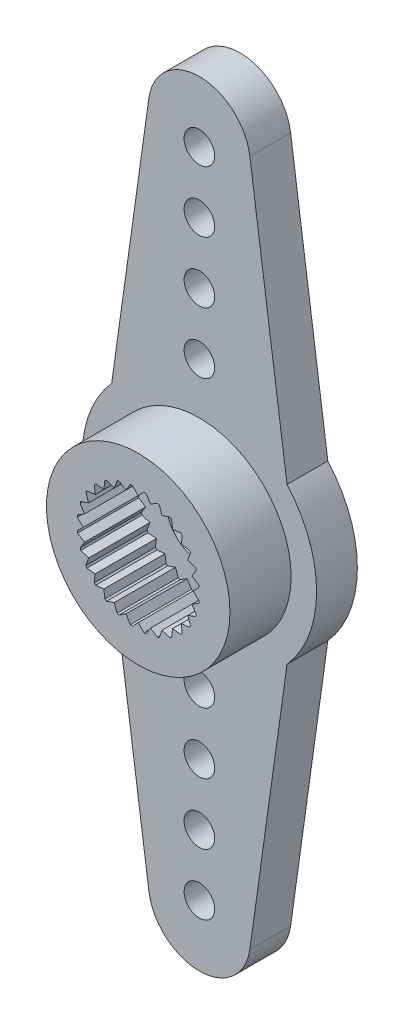
from build123d import *

# Parameters (mm, degrees)
ESQUISSE1_R                  = 5.75
ESQUISSE1_R_2                = 1.6
BOSS_EXTRU_1_DEPTH           = 5
ESQUISSE2_R                  = 3
ENL_V_MAT_EXTRU_1_DEPTH      = 3
ESQUISSE3_R                  = 5.75
ESQUISSE3_R_2                = 4.5
ENL_V_MAT_EXTRU_2_DEPTH      = 3
BOSS_EXTRU_2_DEPTH           = 2
R_P_TITION_CIRCULAIRE1_COUNT = 2
ESQUISSE5_R                  = 0.75
ENL_V_MAT_EXTRU_3_DEPTH      = 3
R_P_TITION_CIRCULAIRE2_COUNT = 2
BOSS_EXTRU_3_DEPTH           = 3
R_P_TITION_CIRCULAIRE3_COUNT = 28
ESQUISSE7_R                  = 3
ESQUISSE7_R_2                = 1.6
ENL_V_MAT_EXTRU_4_DEPTH      = 1
ESQUISSE8_R                  = 4.7
ESQUISSE8_R_2                = 3.4
ENL_V_MAT_EXTRU_5_DEPTH      = 1


with BuildPart() as part:
    # Esquisse1 → Boss.-Extru.1 (new body)
    with BuildSketch(Plane.XY):
        Circle(ESQUISSE1_R)
        Circle(ESQUISSE1_R_2, mode=Mode.SUBTRACT)
    extrude(amount=BOSS_EXTRU_1_DEPTH)

    # Esquisse2 → Enlèv. mat.-Extru.1 (cut)
    with BuildSketch(Plane.XY.offset(5)):
        Circle(ESQUISSE2_R)
    extrude(amount=-ENL_V_MAT_EXTRU_1_DEPTH, mode=Mode.SUBTRACT)

    # Esquisse3 → Enlèv. mat.-Extru.2 (cut)
    with BuildSketch(Plane.XY.offset(5)):
        Circle(ESQUISSE3_R)
        Circle(ESQUISSE3_R_2, mode=Mode.SUBTRACT)
    extrude(amount=-ENL_V_MAT_EXTRU_2_DEPTH, mode=Mode.SUBTRACT)

    # Esquisse4 → Boss.-Extru.2 (add)
    with BuildSketch(Plane(origin=(0, 0, 0), x_dir=(-1, 0, 0), z_dir=(0, 0, -1))):
        with BuildLine():
            Line((-4.3, 3.817394399), (-2.475852955, 16.846629695))
            ThreePointArc((-2.475852955, 16.846629695), (0, 19), (2.475852955, 16.846629695))
            Line((2.475852955, 16.846629695), (4.3, 3.817394399))
            ThreePointArc((4.3, 3.817394399), (0, 5.75), (-4.3, 3.817394399))
        make_face()
    boss_extru_2 = extrude(amount=-BOSS_EXTRU_2_DEPTH)

    # Répétition circulaire1: Boss.-Extru.2 ×2 about axis
    r_p_tition_circulaire1_axis = Axis((0, 0, 0), (0, 0, 1))
    for i in range(1, R_P_TITION_CIRCULAIRE1_COUNT):
        add(boss_extru_2.rotate(r_p_tition_circulaire1_axis, i * 360 / R_P_TITION_CIRCULAIRE1_COUNT))

    # Esquisse5 → Enlèv. mat.-Extru.3 (cut)
    with BuildSketch(Plane(origin=(0, 0, 0), x_dir=(-1, 0, 0), z_dir=(0, 0, -1))):
        with Locations((0, 7)):
            Circle(ESQUISSE5_R)
        with Locations((0, 10)):
            Circle(ESQUISSE5_R)
        with Locations((0, 13)):
            Circle(ESQUISSE5_R)
        with Locations((0, 16)):
            Circle(ESQUISSE5_R)
    enl_v_mat_extru_3 = extrude(amount=-ENL_V_MAT_EXTRU_3_DEPTH, mode=Mode.SUBTRACT)

    # Répétition circulaire2: Enlèv. mat.-Extru.3 ×2 about axis
    r_p_tition_circulaire2_axis = Axis((0, 0, 0), (0, 0, 1))
    for i in range(1, R_P_TITION_CIRCULAIRE2_COUNT):
        add(enl_v_mat_extru_3.rotate(r_p_tition_circulaire2_axis, i * 360 / R_P_TITION_CIRCULAIRE2_COUNT), mode=Mode.SUBTRACT)

    # Esquisse6 → Boss.-Extru.3 (add)
    with BuildSketch(Plane.XY.offset(5)):
        Polygon((-0.3, 3), (0, 2.7), (0.3, 3), align=None)
    boss_extru_3 = extrude(amount=-BOSS_EXTRU_3_DEPTH)

    # Répétition circulaire3: Boss.-Extru.3 ×28 about axis
    r_p_tition_circulaire3_axis = Axis((0, 0, 0), (0, 0, 1))
    for i in range(1, R_P_TITION_CIRCULAIRE3_COUNT):
        add(boss_extru_3.rotate(r_p_tition_circulaire3_axis, i * 360 / R_P_TITION_CIRCULAIRE3_COUNT))

    # Esquisse7 → Enlèv. mat.-Extru.4 (cut)
    with BuildSketch(Plane(origin=(0, 0, 0), x_dir=(-1, 0, 0), z_dir=(0, 0, -1))):
        Circle(ESQUISSE7_R)
        Circle(ESQUISSE7_R_2, mode=Mode.SUBTRACT)
    extrude(amount=-ENL_V_MAT_EXTRU_4_DEPTH, mode=Mode.SUBTRACT)

    # Esquisse8 → Enlèv. mat.-Extru.5 (cut)
    with BuildSketch(Plane(origin=(0, 0, 0), x_dir=(-1, 0, 0), z_dir=(0, 0, -1))):
        Circle(ESQUISSE8_R)
        Circle(ESQUISSE8_R_2, mode=Mode.SUBTRACT)
    extrude(amount=-ENL_V_MAT_EXTRU_5_DEPTH, mode=Mode.SUBTRACT)


solid = part.part
